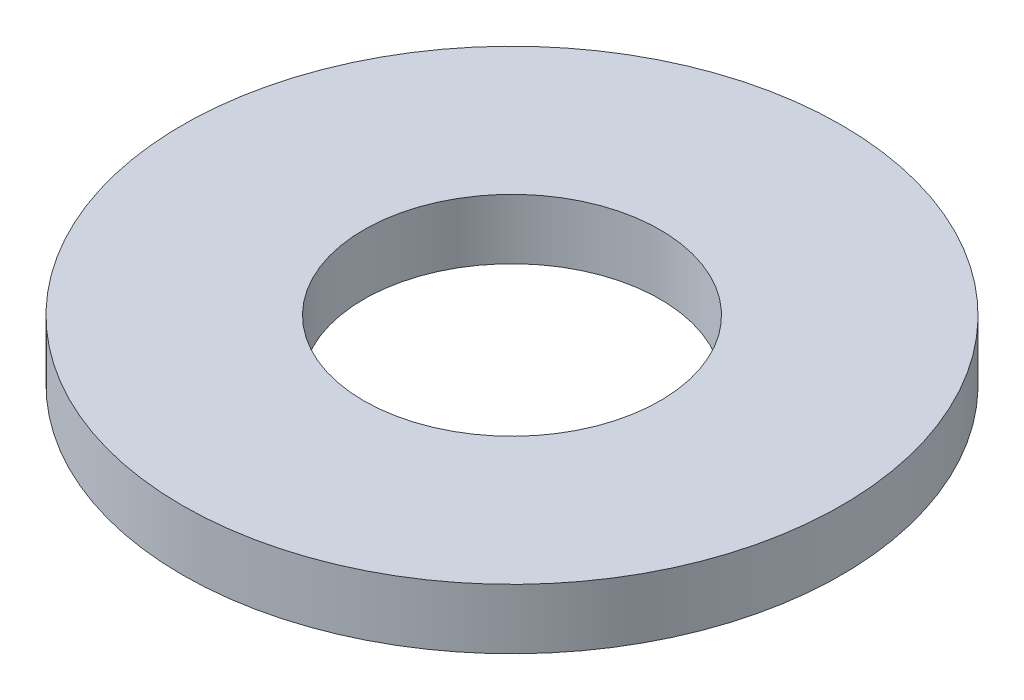
from build123d import *

# Parameters (mm, degrees)
SKETCH1_R           = 7.9375
BOSS_EXTRUDE1_DEPTH = 1.4478
SKETCH5_R           = 3.5687
CUT_EXTRUDE1_DEPTH  = 2.4478


with BuildPart() as part:
    # Sketch1 → Boss-Extrude1 (new body)
    with BuildSketch(Plane(origin=(0, 0, 0), x_dir=(1, 0, 0), z_dir=(0, 1, 0))):
        Circle(SKETCH1_R)
    extrude(amount=BOSS_EXTRUDE1_DEPTH)

    # Sketch5 → Cut-Extrude1 (cut, through all)
    with BuildSketch(Plane(origin=(0, 1.4478, 0), x_dir=(-1, 0, 0), z_dir=(0, 1, 0))):
        Circle(SKETCH5_R)
    extrude(amount=-CUT_EXTRUDE1_DEPTH, mode=Mode.SUBTRACT)


solid = part.part
